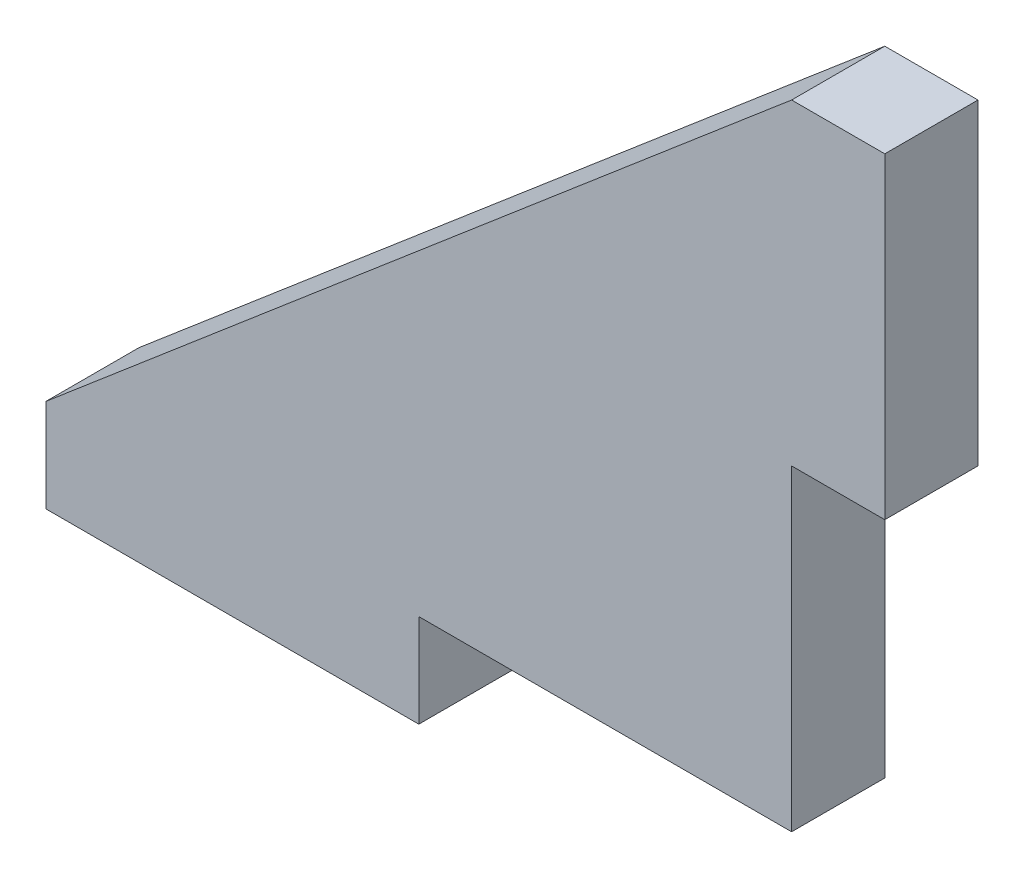
from build123d import *

# Parameters (mm, degrees)
CROQUIS1_W              = 5
CROQUIS1_H              = 17
CROQUIS1_W_2            = 20
CROQUIS1_H_2            = 5
SALIENTE_EXTRUIR1_DEPTH = 5


with BuildPart() as part:
    # Croquis1 → Saliente-Extruir1 (new body)
    with BuildSketch(Plane.XY):
        with Locations((42.5, 25.5)):
            Rectangle(CROQUIS1_W, CROQUIS1_H)
        Polygon((40, 0), (0, 0), (40, 34), align=None)
        with Locations((10, -2.5)):
            Rectangle(CROQUIS1_W_2, CROQUIS1_H_2)
    extrude(amount=SALIENTE_EXTRUIR1_DEPTH)


solid = part.part
